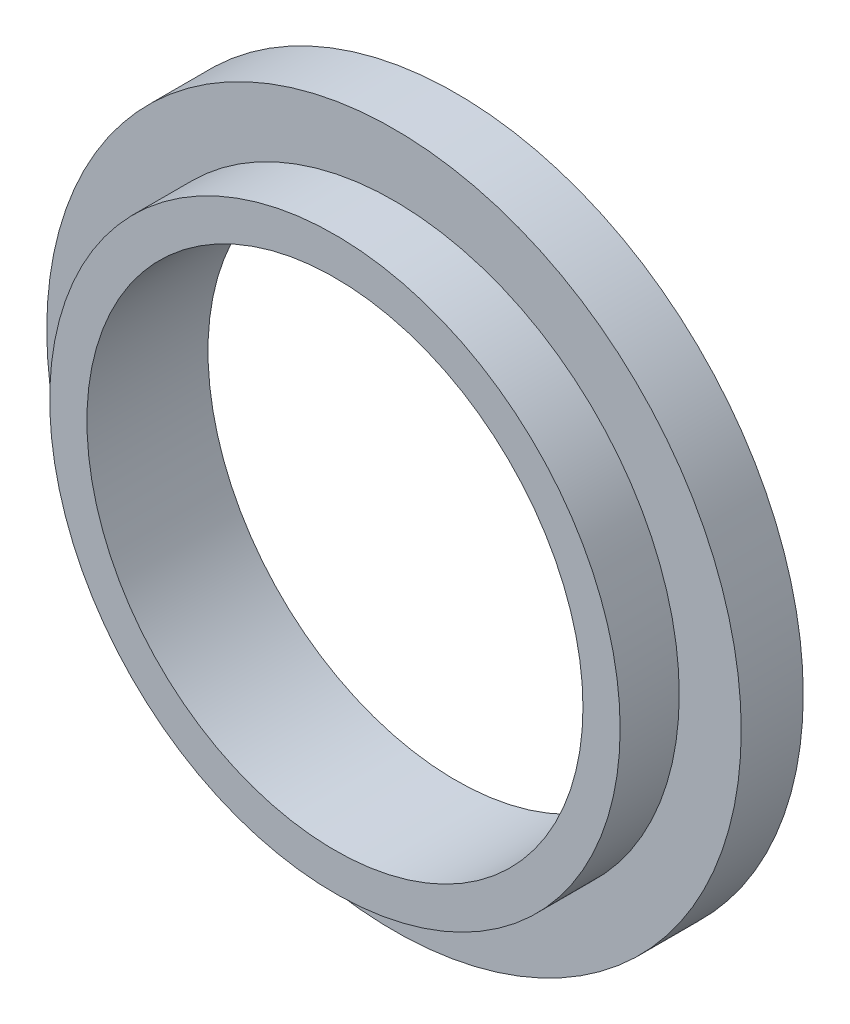
from build123d import *

# Parameters (mm, degrees)
SKETCH1_R               = 28
BOSS_EXTRUDE1_DEPTH     = 5
SKETCH2_R               = 23
BOSS_EXTRUDE2_DEPTH     = 4.7625
SKETCH3_R               = 20
CUT_EXTRUDE1_DEPTH      = 1
CUT_EXTRUDE1_DEPTH_BACK = 10.7625


with BuildPart() as part:
    # Sketch1 → Boss-Extrude1 (new body)
    with BuildSketch(Plane.XY):
        Circle(SKETCH1_R)
    extrude(amount=BOSS_EXTRUDE1_DEPTH)

    # Sketch2 → Boss-Extrude2 (add)
    with BuildSketch(Plane.XY.offset(5)):
        Circle(SKETCH2_R)
    extrude(amount=BOSS_EXTRUDE2_DEPTH)

    # Sketch3 → Cut-Extrude1 (cut, two sides)
    with BuildSketch(Plane.XY.offset(9.7625)) as cut_extrude1_sk:
        Circle(SKETCH3_R)
    extrude(amount=CUT_EXTRUDE1_DEPTH, mode=Mode.SUBTRACT)
    extrude(cut_extrude1_sk.sketch, amount=-CUT_EXTRUDE1_DEPTH_BACK, mode=Mode.SUBTRACT)


solid = part.part
